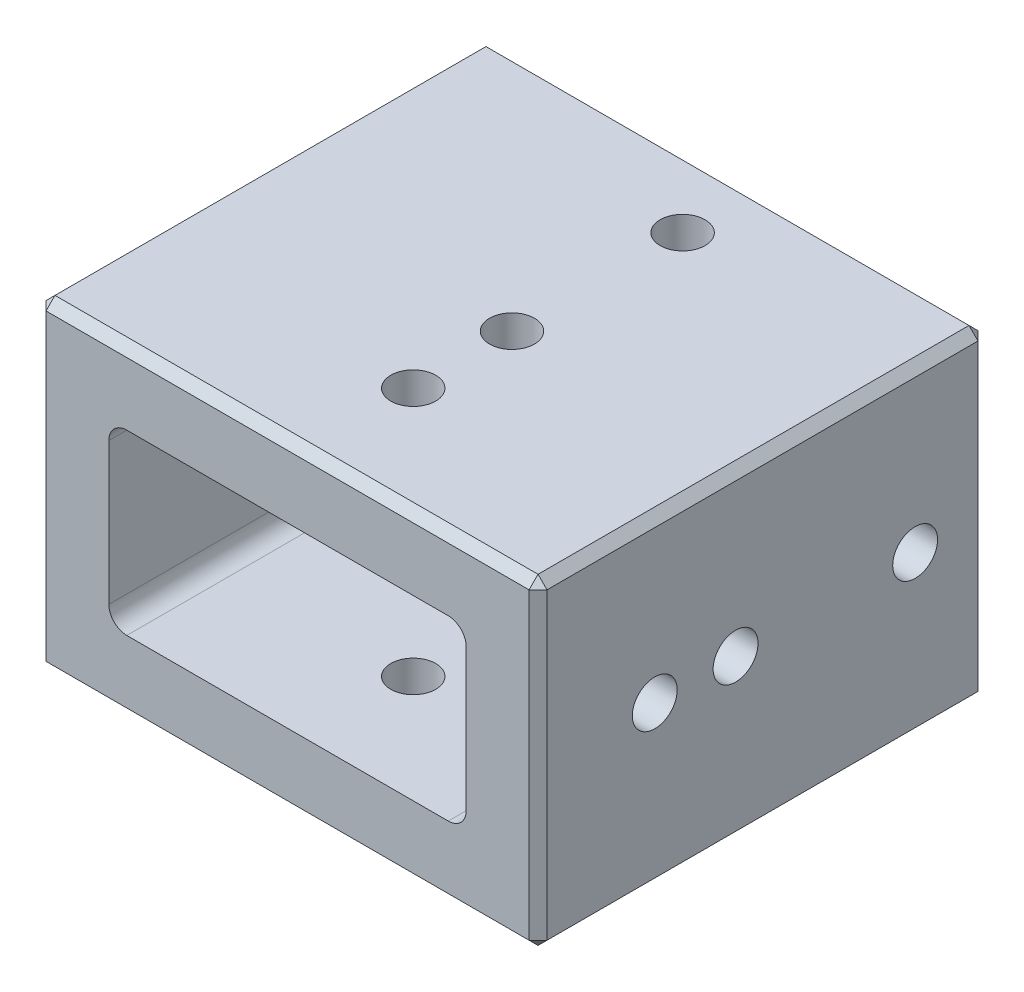
from build123d import *

# Parameters (mm, degrees)
SKETCH_2_W             = 27.9
SKETCH_2_H             = 17.9
EXTRUDE_1_DEPTH        = 12.5
HOLE_WIZARD_M3_1_D     = 2.5
HOLE_WIZARD_M3_2_D     = 2.5
HOLE_WIZARD_M3_3_D     = 2.5
SKETCH_9_W             = 19.9
SKETCH_9_H             = 9.9
CUT_EXTRUDE_1_DEPTH    = 26
CHAMFER_2_SIZE         = 0.5
HOLE_WIZARD_M3_4_D     = 2.5
HOLE_WIZARD_M3_6_D     = 2.5
HOLE_WIZARD_M3_6_DEPTH = 4
HOLE_WIZARD_M3_7_D     = 2.5
FILLET_1_R             = 1


with BuildPart() as part:
    # 草图2 → 凸台-拉伸1 (new body, symmetric)
    with BuildSketch(Plane.XY):
        Rectangle(SKETCH_2_W, SKETCH_2_H)
    extrude(amount=EXTRUDE_1_DEPTH, both=True)

    # M3 螺纹孔1 (through all)
    with Locations(Plane(origin=(1, -8.95, -8.5), x_dir=(0, 0, -1), z_dir=(0, -1, 0))):
        with Locations((0, 0)):
            Hole(HOLE_WIZARD_M3_1_D / 2)

    # M3 螺纹孔2 (through all)
    with Locations(Plane(origin=(-13.95, 0, -8.5), x_dir=(0, 0, -1), z_dir=(-1, 0, 0))):
        with Locations((0, 0)):
            Hole(HOLE_WIZARD_M3_2_D / 2)

    # M3 螺纹孔3 (through all)
    with Locations(Plane(origin=(1, -8.95, 6.5), x_dir=(0, 0, -1), z_dir=(0, -1, 0))):
        with Locations((0, 0)):
            Hole(HOLE_WIZARD_M3_3_D / 2)

    # 草图9 → 切除-拉伸1 (cut, through all)
    with BuildSketch(Plane(origin=(0, 0, -12.5), x_dir=(-1, 0, 0), z_dir=(0, 0, -1))):
        Rectangle(SKETCH_9_W, SKETCH_9_H)
    extrude(amount=-CUT_EXTRUDE_1_DEPTH, mode=Mode.SUBTRACT)

    # 倒角2
    chamfer_2_edges = [part.edges().sort_by_distance(p)[0] for p in [
        (-13.95, 0, 12.5),
        (0, -8.95, 12.5),
        (13.95, 0, 12.5),
        (0, -8.95, -12.5),
        (-13.95, 0, -12.5),
        (0, 8.95, -12.5),
        (13.95, 0, -12.5),
        (13.95, -8.95, 0),
        (-13.95, -8.95, 0),
        (-13.95, 8.95, 0),
        (13.95, 8.95, 0),
        (0, 8.95, 12.5),
    ]]
    chamfer(chamfer_2_edges, length=CHAMFER_2_SIZE)

    # M3 螺纹孔4 (through all)
    with Locations(Plane(origin=(13.95, 0, 1.5), x_dir=(0, 0, 1), z_dir=(1, 0, 0))):
        with Locations((0, 0)):
            Hole(HOLE_WIZARD_M3_4_D / 2)

    # M3 螺纹孔6
    with Locations(Plane(origin=(13.95, 0, 6), x_dir=(0, 0, 1), z_dir=(1, 0, 0))):
        with Locations((0, 0)):
            Hole(HOLE_WIZARD_M3_6_D / 2, depth=HOLE_WIZARD_M3_6_DEPTH)

    # M3 螺纹孔7 (through all)
    with Locations(Plane(origin=(1, 8.95, 1), x_dir=(0, 0, 1), z_dir=(0, 1, 0))):
        with Locations((0, 0)):
            Hole(HOLE_WIZARD_M3_7_D / 2)

    # 圆角1
    fillet_1_edges = [part.edges().sort_by_distance(p)[0] for p in [
        (-9.95, 4.95, 0),
        (9.95, -4.95, 0),
        (9.95, 4.95, 0),
        (-9.95, -4.95, 0),
    ]]
    fillet(fillet_1_edges, radius=FILLET_1_R)


solid = part.part
